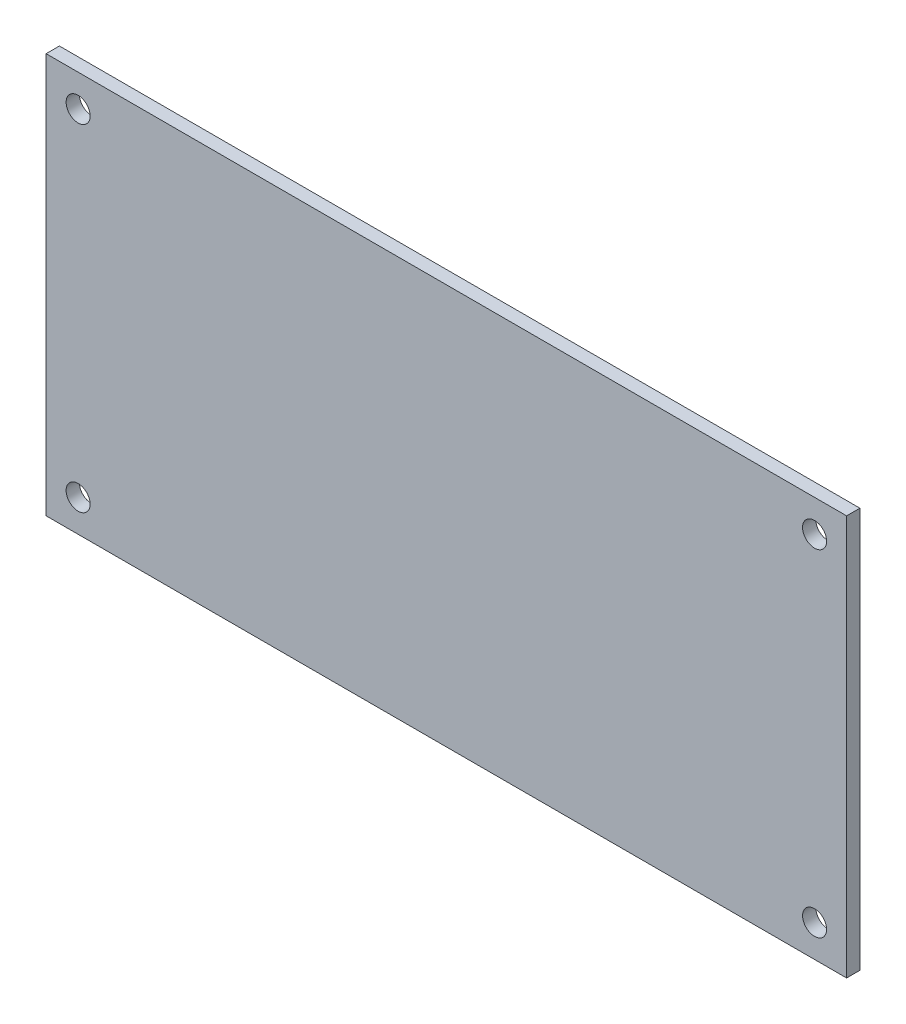
from build123d import *

# Parameters (mm, degrees)
ESQUISSE1_W        = 100
ESQUISSE1_H        = 50
ESQUISSE1_R        = 1.5
BOSS_EXTRU_1_DEPTH = 1.66


with BuildPart() as part:
    # Esquisse1 → Boss.-Extru.1 (new body)
    with BuildSketch(Plane.XY):
        Rectangle(ESQUISSE1_W, ESQUISSE1_H)
        with Locations((-46, 21)):
            Circle(ESQUISSE1_R, mode=Mode.SUBTRACT)
        with Locations((-46, -21)):
            Circle(ESQUISSE1_R, mode=Mode.SUBTRACT)
        with Locations((46, 21)):
            Circle(ESQUISSE1_R, mode=Mode.SUBTRACT)
        with Locations((46, -21)):
            Circle(ESQUISSE1_R, mode=Mode.SUBTRACT)
    extrude(amount=BOSS_EXTRU_1_DEPTH)


solid = part.part
